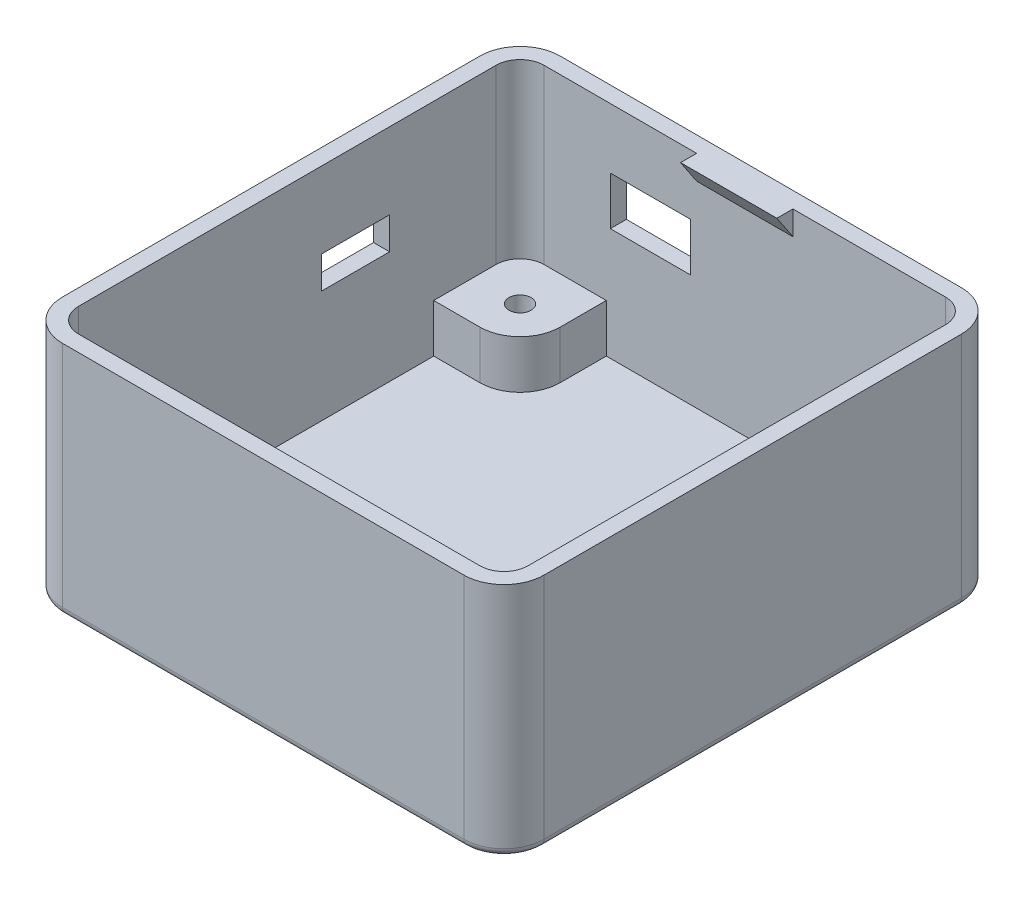
from build123d import *

# Parameters (mm, degrees)
BOSS_EXTRUDE1_DEPTH = 29.5
CUT_EXTRUDE1_DEPTH  = 27.5
SKETCH4_R           = 1.375
BOSS_EXTRUDE2_DEPTH = 6
CUT_EXTRUDE2_REACH  = 62
SKETCH5_W           = 8.5
SKETCH5_H           = 4
CUT_EXTRUDE3_REACH  = 64
SKETCH6_W           = 10
SKETCH6_H           = 6
BOSS_EXTRUDE3_DEPTH = 12
FILLET1_R           = 1


with BuildPart() as part:
    # Sketch1 → Boss-Extrude1 (new body)
    with BuildSketch(Plane(origin=(0, 0, 0), x_dir=(1, 0, 0), z_dir=(0, 1, 0))):
        with BuildLine():
            Line((-25, -31), (25, -31))
            ThreePointArc((25, -31), (28.535533906, -29.535533906), (30, -26))
            Line((30, -26), (30, 26))
            ThreePointArc((30, 26), (28.535533906, 29.535533906), (25, 31))
            Line((25, 31), (-25, 31))
            ThreePointArc((-25, 31), (-28.535533906, 29.535533906), (-30, 26))
            Line((-30, 26), (-30, -26))
            ThreePointArc((-30, -26), (-28.535533906, -29.535533906), (-25, -31))
        make_face()
    extrude(amount=BOSS_EXTRUDE1_DEPTH)

    # Sketch2 → Cut-Extrude1 (cut)
    with BuildSketch(Plane(origin=(0, 29.5, 0), x_dir=(1, 0, 0), z_dir=(0, 1, 0))):
        with BuildLine():
            Line((-25, -29), (25, -29))
            ThreePointArc((25, -29), (27.121320344, -28.121320344), (28, -26))
            Line((28, -26), (28, 26))
            ThreePointArc((28, 26), (27.121320344, 28.121320344), (25, 29))
            Line((25, 29), (-25, 29))
            ThreePointArc((-25, 29), (-27.121320344, 28.121320344), (-28, 26))
            Line((-28, 26), (-28, -26))
            ThreePointArc((-28, -26), (-27.121320344, -28.121320344), (-25, -29))
        make_face()
    extrude(amount=-CUT_EXTRUDE1_DEPTH, mode=Mode.SUBTRACT)

    # Sketch4 → Boss-Extrude2 (add)
    with BuildSketch(Plane(origin=(0, 2, 0), x_dir=(1, 0, 0), z_dir=(0, 1, 0))):
        with BuildLine():
            Line((-17.25, 23.25), (-17.25, 29))
            Line((-17.25, 29), (-25, 29))
            ThreePointArc((-25, 29), (-27.121320344, 28.121320344), (-28, 26))
            Line((-28, 26), (-28, 18.25))
            Line((-28, 18.25), (-22.25, 18.25))
            ThreePointArc((-22.25, 18.25), (-18.714466094, 19.714466094), (-17.25, 23.25))
        make_face()
        with Locations((-22.25, 23.25)):
            Circle(SKETCH4_R, mode=Mode.SUBTRACT)
        with BuildLine():
            Line((22.25, 18.25), (28, 18.25))
            Line((28, 18.25), (28, 26))
            ThreePointArc((28, 26), (27.121320344, 28.121320344), (25, 29))
            Line((25, 29), (17.25, 29))
            Line((17.25, 29), (17.25, 23.25))
            ThreePointArc((17.25, 23.25), (18.714466094, 19.714466094), (22.25, 18.25))
        make_face()
        with Locations((22.25, 23.25)):
            Circle(SKETCH4_R, mode=Mode.SUBTRACT)
        with BuildLine():
            Line((-25, -29), (-17.25, -29))
            Line((-17.25, -29), (-17.25, -23.25))
            ThreePointArc((-17.25, -23.25), (-18.714466094, -19.714466094), (-22.25, -18.25))
            Line((-22.25, -18.25), (-28, -18.25))
            Line((-28, -18.25), (-28, -26))
            ThreePointArc((-28, -26), (-27.121320344, -28.121320344), (-25, -29))
        make_face()
        with Locations((-22.25, -23.25)):
            Circle(SKETCH4_R, mode=Mode.SUBTRACT)
        with BuildLine():
            Line((28, -26), (28, -18.25))
            Line((28, -18.25), (22.25, -18.25))
            ThreePointArc((22.25, -18.25), (18.714466094, -19.714466094), (17.25, -23.25))
            Line((17.25, -23.25), (17.25, -29))
            Line((17.25, -29), (25, -29))
            ThreePointArc((25, -29), (27.121320344, -28.121320344), (28, -26))
        make_face()
        with Locations((22.25, -23.25)):
            Circle(SKETCH4_R, mode=Mode.SUBTRACT)
    extrude(amount=BOSS_EXTRUDE2_DEPTH)

    # Sketch5 → Cut-Extrude2 (cut, up to next)
    with BuildSketch(Plane.ZY.offset(30), mode=Mode.PRIVATE) as cut_extrude2_sk1:
        with Locations((-8.5, 18)):
            Rectangle(SKETCH5_W, SKETCH5_H)
    cut_extrude2_tool1 = extrude(cut_extrude2_sk1.sketch, amount=-CUT_EXTRUDE2_REACH, mode=Mode.PRIVATE) & part.part
    add(cut_extrude2_tool1.solids().sort_by_distance((-30, 18, -8.5))[0], mode=Mode.SUBTRACT)

    # Sketch6 → Cut-Extrude3 (cut, up to next)
    with BuildSketch(Plane(origin=(0, 0, -31), x_dir=(-1, 0, 0), z_dir=(0, 0, -1)), mode=Mode.PRIVATE) as cut_extrude3_sk1:
        with Locations((11.75, 19)):
            Rectangle(SKETCH6_W, SKETCH6_H)
    cut_extrude3_tool1 = extrude(cut_extrude3_sk1.sketch, amount=-CUT_EXTRUDE3_REACH, mode=Mode.PRIVATE) & part.part
    add(cut_extrude3_tool1.solids().sort_by_distance((-11.75, 19, -31))[0], mode=Mode.SUBTRACT)

    # Sketch7 → Boss-Extrude3 (add)
    with BuildSketch(Plane.ZY.offset(6)):
        Polygon((-29, 29.5), (-29, 26.5), (-27, 29.5), align=None)
    extrude(amount=-BOSS_EXTRUDE3_DEPTH)

    # Fillet1
    fillet1_edges = [part.edges().sort_by_distance(p)[0] for p in [
        (0, 0, -31),
        (28.535533906, 0, -29.535533906),
        (30, 0, 0),
        (28.535533906, 0, 29.535533906),
        (0, 0, 31),
        (-28.535533906, 0, 29.535533906),
        (-30, 0, 0),
        (-28.535533906, 0, -29.535533906),
    ]]
    fillet(fillet1_edges, radius=FILLET1_R)


solid = part.part
